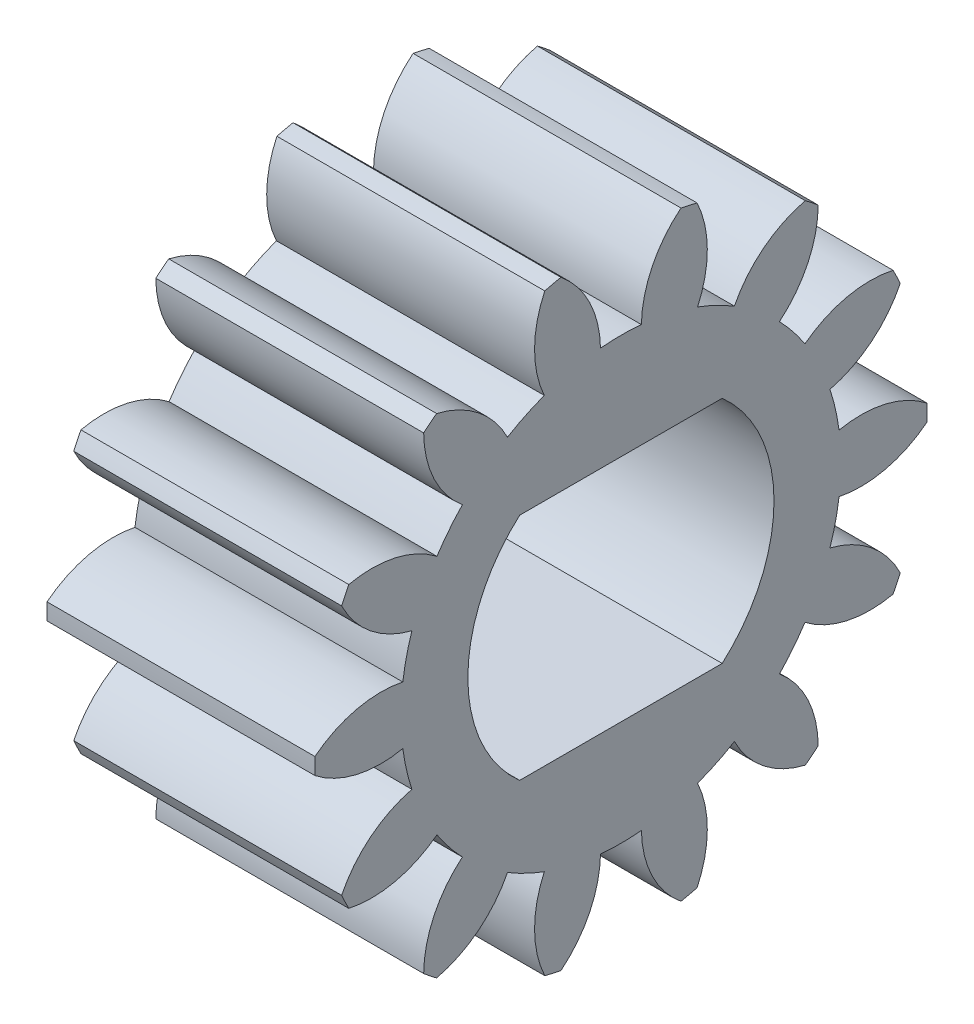
from build123d import *

# Parameters (mm, degrees)
BASPROSKE_W        = 14
BASPROSKE_H        = 16
TOOTHCUT_DEPTH     = 27.608269391
TEETHCUTS_COUNT    = 14
TEETHCUTS_ANGLE    = 334.285714286
BORSKE_R           = 0.4
BORE_DEPTH         = 50.0000508
CUT_EXTRUDE1_DEPTH = 27.422624507


with BuildPart() as part:
    # BasProSke → Base-Revolve (revolve)
    with BuildSketch(Plane(origin=(0, 0, 0), x_dir=(1, 0, 0), z_dir=(0, 1, 0)), mode=Mode.PRIVATE) as base_revolve_sk:
        with Locations((7, 8)):
            Rectangle(BASPROSKE_W, BASPROSKE_H)
    revolve(base_revolve_sk.sketch.rotate(Axis((-10, 0, 0), (1, 0, 0)), 180), axis=Axis((-10, 0, 0), (1, 0, 0)))

    # TooCutSke → ToothCut (cut, through all)
    with BuildSketch(Plane(origin=(0, 0, 0), x_dir=(0, 0, -1), z_dir=(1, 0, 0))):
        with BuildLine():
            ThreePointArc((1.067858192, 11.449309144), (0, 11.499), (-1.067858192, 11.449309144))
            ThreePointArc((-1.067858192, 11.449309144), (-1.641684211, 13.812780716), (-3.163375005, 15.710076503))
            ThreePointArc((-3.163375005, 15.710076503), (0, 16.0254), (3.163375005, 15.710076503))
            ThreePointArc((3.163375005, 15.710076503), (1.641684211, 13.812780716), (1.067858192, 11.449309144))
        make_face()
    toothcut = extrude(amount=TOOTHCUT_DEPTH, mode=Mode.SUBTRACT)

    # TeethCuts: ToothCut ×14 about axis
    teethcuts_axis = Axis((-10, 0, 0), (1, 0, 0))
    for i in range(1, TEETHCUTS_COUNT):
        add(toothcut.rotate(teethcuts_axis, i * TEETHCUTS_ANGLE / (TEETHCUTS_COUNT - 1)), mode=Mode.SUBTRACT)

    # BorSke → Bore (cut, symmetric)
    with BuildSketch(Plane(origin=(0, 0, 0), x_dir=(0, 0, -1), z_dir=(1, 0, 0))):
        with Locations(Location((0, 0, 0), (0, 0, 180))):
            Circle(BORSKE_R)
    extrude(amount=BORE_DEPTH, both=True, mode=Mode.SUBTRACT)

    # Sketch1 → Cut-Extrude1 (cut, through all)
    with BuildSketch(Plane(origin=(14, 0, 0), x_dir=(0, 0, -1), z_dir=(1, 0, 0))):
        with BuildLine():
            Line((-5.291502622, 6), (5.291502622, 6))
            ThreePointArc((5.291502622, 6), (8, 0), (5.291502622, -6))
            Line((5.291502622, -6), (-5.291502622, -6))
            ThreePointArc((-5.291502622, -6), (-8, 0), (-5.291502622, 6))
        make_face()
    extrude(amount=-CUT_EXTRUDE1_DEPTH, mode=Mode.SUBTRACT)

    # Sketch3 → Cut-Revolve2 (revolve, cut)
    with BuildSketch(Plane(origin=(0, 0, 0), x_dir=(1, 0, 0), z_dir=(0, 1, 0)), mode=Mode.PRIVATE) as cut_revolve2_sk:
        Polygon((0, 0), (2.289763839, 0), (2.289763839, 9), (-2.541437219, 11.109912375), (-2.541437219, 0), align=None)
    revolve(cut_revolve2_sk.sketch.rotate(Axis((-21.436119779, 0, 0), (1, 0, 0)), 180), axis=Axis((-21.436119779, 0, 0), (1, 0, 0)), mode=Mode.SUBTRACT)


solid = part.part
